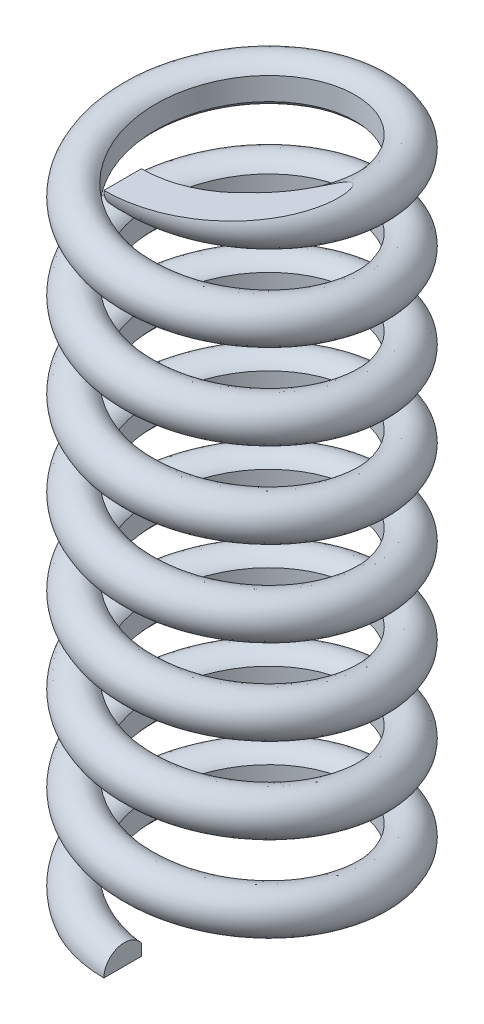
from build123d import *

# Parameters (mm, degrees)
SWEEP1_PITCH            = 2.5
SWEEP1_HEIGHT           = 20
SWEEP1_RADIUS           = 3.45
SKETCH2_R               = 0.6
SKETCH3_W               = 10
SKETCH3_H               = 1
CUT_EXTRUDE1_DEPTH      = 43
SKETCH4_W               = 10
SKETCH4_H               = 1
CUT_EXTRUDE2_DEPTH      = 43
SKETCH5_R               = 2.95
CUT_EXTRUDE4_DEPTH      = 21.803966057
CUT_EXTRUDE4_DEPTH_BACK = 21.803966057


with BuildPart() as part:
    # Sweep1: sweep along a helix
    with BuildLine() as sweep1_path:
        Helix(SWEEP1_PITCH, SWEEP1_HEIGHT, SWEEP1_RADIUS, center=(0, 0, 0), direction=(0, 1, 0), lefthand=True)
    # Sketch2 → Sweep1 (sweep)
    with BuildSketch(Plane(origin=(0, 0, 0), x_dir=(0, 0, -1), z_dir=(1, 0, 0))):
        with Locations((-3.45, 0)):
            Circle(SKETCH2_R)
    sweep(path=sweep1_path.line, is_frenet=True)

    # Sketch3 → Cut-Extrude1 (cut)
    with BuildSketch(Plane(origin=(0, 0, 0), x_dir=(0, 0, -1), z_dir=(1, 0, 0))):
        with Locations((0, -0.5)):
            Rectangle(SKETCH3_W, SKETCH3_H)
    extrude(amount=-CUT_EXTRUDE1_DEPTH, mode=Mode.SUBTRACT)

    # Sketch4 → Cut-Extrude2 (cut)
    with BuildSketch(Plane.ZY):
        with Locations((0, 20.5)):
            Rectangle(SKETCH4_W, SKETCH4_H)
    extrude(amount=-CUT_EXTRUDE2_DEPTH, mode=Mode.SUBTRACT)

    # Sketch5 → Cut-Extrude4 (cut, two sides)
    with BuildSketch(Plane(origin=(0, 0, 0), x_dir=(1, 0, 0), z_dir=(0, 1, 0))) as cut_extrude4_sk:
        Circle(SKETCH5_R)
    extrude(amount=CUT_EXTRUDE4_DEPTH, mode=Mode.SUBTRACT)
    extrude(cut_extrude4_sk.sketch, amount=-CUT_EXTRUDE4_DEPTH_BACK, mode=Mode.SUBTRACT)


solid = part.part
